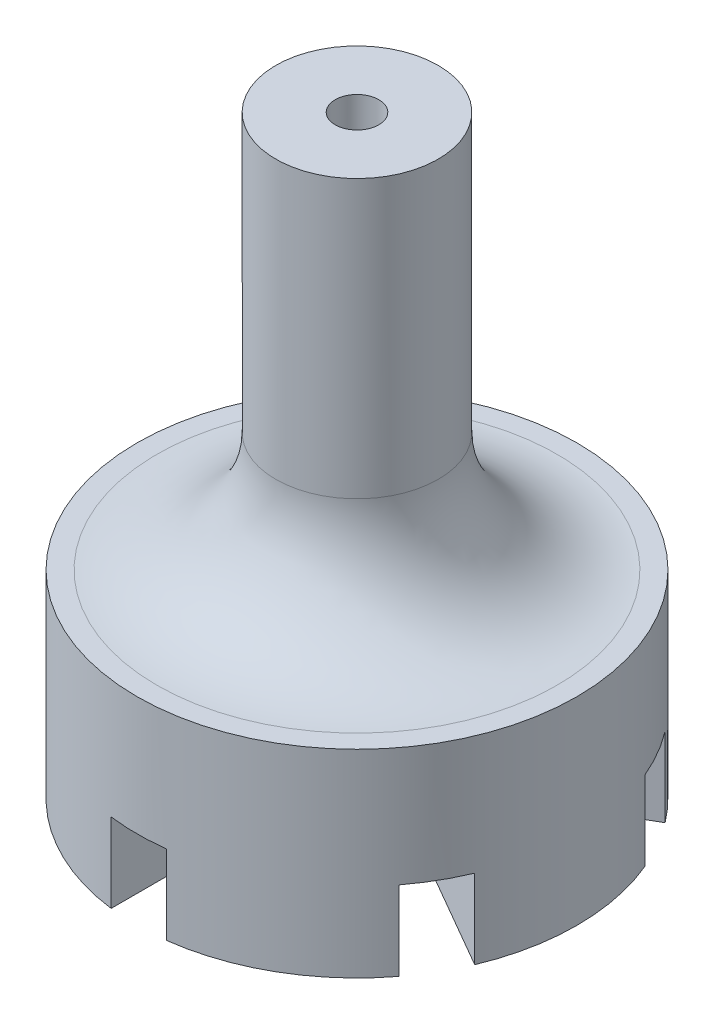
from build123d import *

# Parameters (mm, degrees)
CORTE_EXTRUS_O2_DEPTH = 2
FILETE1_R             = 3


with BuildPart() as part:
    # Esboço1 → Revolução1 (revolve)
    with BuildSketch(Plane.XY):
        Polygon((0.55, 10), (2.05, 10), (2.05, 0), (5.55, 0), (5.55, -5), (0.55, -5), align=None)
    revolve(axis=Axis((0, 0, 0), (0, 1, 0)))

    # Esboço2 → Corte-extrusão2 (cut)
    with BuildSketch(Plane.XZ.offset(5)):
        Polygon((-0.7, 5.55), (-0.7, 1.212435565), (-4.456440991, 3.381217783), (-5.156440991, 2.168782217), (-1.4, 0), (-5.156440991, -2.168782217), (-4.456440991, -3.381217783), (-0.7, -1.212435565), (-0.7, -5.55), (0.7, -5.55), (0.7, -1.212435565), (4.456440991, -3.381217783), (5.156440991, -2.168782217), (1.4, 0), (5.156440991, 2.168782217), (4.456440991, 3.381217783), (0.7, 1.212435565), (0.7, 5.55), align=None)
    extrude(amount=-CORTE_EXTRUS_O2_DEPTH, mode=Mode.SUBTRACT)

    # Filete1
    filete1_edges = [part.edges().sort_by_distance(p)[0] for p in [
        (-2.05, 0, 0),
    ]]
    fillet(filete1_edges, radius=FILETE1_R)


solid = part.part
